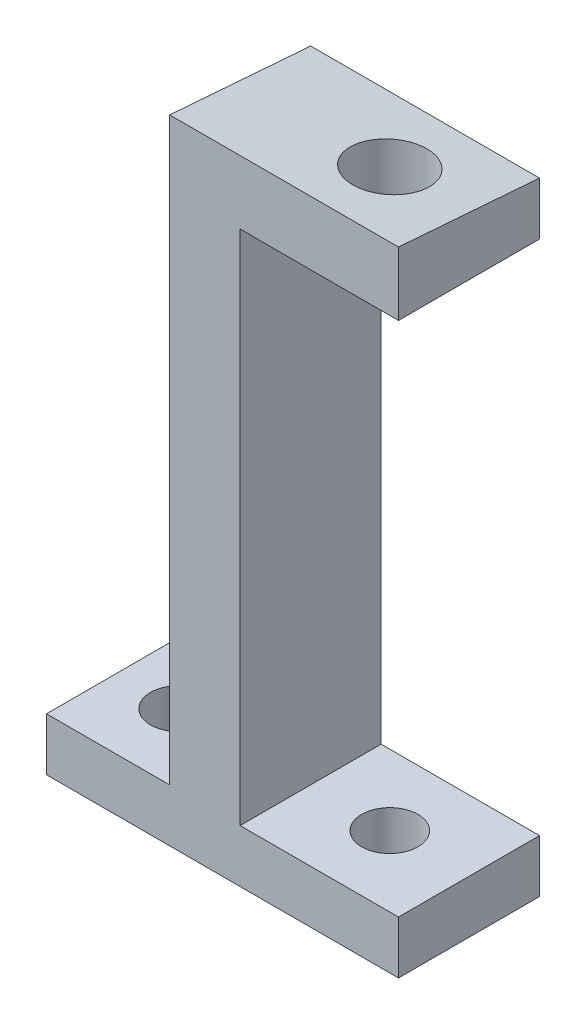
from build123d import *

# Parameters (mm, degrees)
SKETCH1_W             = 8.012892266
SKETCH1_H             = 3
BOSS_EXTRUDE1_DEPTH   = 9
BOSS_EXTRUDE1_2_DEPTH = 9
BOSS_EXTRUDE2_START   = -9
BOSS_EXTRUDE2_DEPTH   = 4
BOSS_EXTRUDE3_START   = -13
SKETCH1_4_W           = 8.012892266
SKETCH1_4_H           = 3
BOSS_EXTRUDE3_DEPTH   = 7
CUT_EXTRUDE1_REACH    = 136.557
SKETCH2_R             = 1.6
CUT_EXTRUDE2_REACH    = 136.408
SKETCH3_R             = 2.1


with BuildPart() as part:
    # Sketch1 → Boss-Extrude1 (new body)
    with BuildSketch(Plane(origin=(-20.116663772, 0, 0), x_dir=(0, 0, -1), z_dir=(1, 0, 0))):
        with Locations((120.127472222, 75.181369419)):
            Rectangle(SKETCH1_W, SKETCH1_H)
    extrude(amount=-BOSS_EXTRUDE1_DEPTH)



with BuildPart() as body_2:
    # Sketch1 → Boss-Extrude1 2 (new body)
    with BuildSketch(Plane(origin=(-20.116663772, 0, 0), x_dir=(0, 0, -1), z_dir=(1, 0, 0))):
        Polygon((116.121026089, 106.035971289), (124.133918355, 106.035971289), (124.133918355, 109.035971289), (116.121026089, 109.651271917), align=None)
    extrude(amount=-BOSS_EXTRUDE1_2_DEPTH)


with BuildPart() as part_1:
    add(part.part)

    add(body_2.part)  # Boss-Extrude2 merges body 2
    # Sketch1_3 → Boss-Extrude2 (add)
    with BuildSketch(Plane(origin=(-20.116663772, 0, 0), x_dir=(0, 0, -1), z_dir=(1, 0, 0)).offset(BOSS_EXTRUDE2_START)):
        Polygon((116.121026089, 73.681369419), (124.133918355, 73.681369419), (124.133918355, 109.035971289), (116.121026089, 109.651271917), align=None)
    extrude(amount=-BOSS_EXTRUDE2_DEPTH)

    # Sketch1_4 → Boss-Extrude3 (add)
    with BuildSketch(Plane(origin=(-20.116663772, 0, 0), x_dir=(0, 0, -1), z_dir=(1, 0, 0)).offset(BOSS_EXTRUDE3_START)):
        with Locations((120.127472222, 75.181369419)):
            Rectangle(SKETCH1_4_W, SKETCH1_4_H)
    extrude(amount=-BOSS_EXTRUDE3_DEPTH)

    # Sketch2 → Cut-Extrude1 (cut, up to next)
    with BuildSketch(Plane(origin=(0, 76.681369419, 0), x_dir=(1, 0, 0), z_dir=(0, 1, 0)), mode=Mode.PRIVATE) as cut_extrude1_sk1:
        with Locations(Location((-24.616663772, 120.127472222, 0), (0, 0, 180))):
            Circle(SKETCH2_R)
    cut_extrude1_tool1 = extrude(cut_extrude1_sk1.sketch, amount=-CUT_EXTRUDE1_REACH, mode=Mode.PRIVATE) & part_1.part
    # Sketch2 → Cut-Extrude1 (cut, up to next)
    with BuildSketch(Plane(origin=(0, 76.681369419, 0), x_dir=(1, 0, 0), z_dir=(0, 1, 0)), mode=Mode.PRIVATE) as cut_extrude1_sk2:
        with Locations(Location((-36.616663772, 120.127472222, 0), (0, 0, 180))):
            Circle(SKETCH2_R)
    cut_extrude1_tool2 = extrude(cut_extrude1_sk2.sketch, amount=-CUT_EXTRUDE1_REACH, mode=Mode.PRIVATE) & part_1.part
    add(cut_extrude1_tool1.solids().sort_by_distance((-24.616664, 76.681369, -120.127472))[0], mode=Mode.SUBTRACT)
    add(cut_extrude1_tool2.solids().sort_by_distance((-36.616664, 76.681369, -120.127472))[0], mode=Mode.SUBTRACT)

    # Cut-Extrude2: up to this plane
    cut_extrude2_end = Plane(origin=(-33.116663772, 117.873028528, -9.051332034), z_dir=(1.1764260283030438e-15, -0.9970647123754436, 0.07656343341095784))
    # Sketch3 → Cut-Extrude2 (cut, up to the surface)
    with BuildSketch(Plane.XZ.offset(-106.035971289), mode=Mode.PRIVATE) as cut_extrude2_sk1:
        with Locations((-24.616663772, -120.127472222)):
            Circle(SKETCH3_R)
    cut_extrude2_tool1 = split(extrude(cut_extrude2_sk1.sketch, amount=-CUT_EXTRUDE2_REACH, mode=Mode.PRIVATE), bisect_by=cut_extrude2_end, keep=Keep.BOTH, mode=Mode.PRIVATE)
    add(cut_extrude2_tool1.solids().sort_by_distance((-24.616664, 106.035971, -120.127472))[0], mode=Mode.SUBTRACT)


solid = part_1.part
